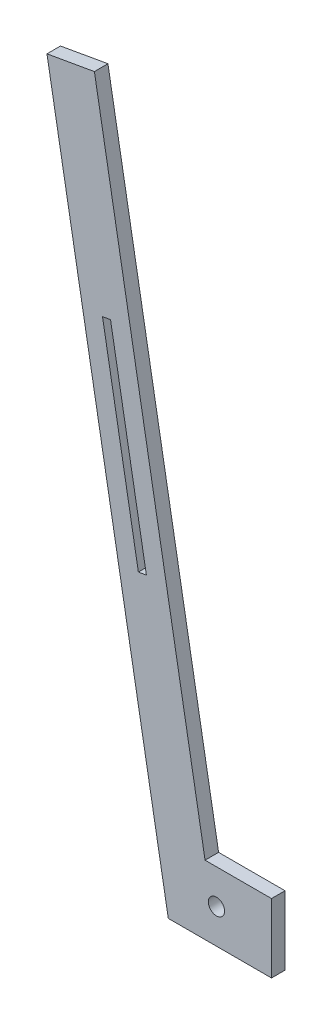
from build123d import *

# Parameters (mm, degrees)
SKETCH1_R           = 3
BOSS_EXTRUDE1_DEPTH = 2.5
CUT_EXTRUDE1_DEPTH  = 6
CUT_EXTRUDE2_DEPTH  = 25.4


with BuildPart() as part:
    # Sketch1 → Boss-Extrude1 (new body, symmetric)
    with BuildSketch(Plane.XY):
        Polygon((20.32, 12.7), (20.32, -12.7), (-17.78, -12.7), (-62.5670531, 241.3), (-37.552936173, 245.710663713), (3.533130632, 12.7), align=None)
        Circle(SKETCH1_R, mode=Mode.SUBTRACT)
    extrude(amount=BOSS_EXTRUDE1_DEPTH, both=True)

    # Sketch2 → Cut-Extrude1 (cut, through all)
    with BuildSketch(Plane.XY.offset(2.5)):
        Polygon((-37.552936173, 245.710663713), (3.533130632, 12.7), (-4.204420151, 12.7), (-45.057171251, 244.387464599), align=None)
    extrude(amount=-CUT_EXTRUDE1_DEPTH, mode=Mode.SUBTRACT)

    # Sketch3 → Cut-Extrude2 (cut, symmetric)
    with BuildSketch(Plane.XY):
        Polygon((-42.057332667, 167.540909253), (-39.102909408, 168.061853786), (-25.87091827, 93.019503007), (-28.825341529, 92.498558474), align=None)
    extrude(amount=CUT_EXTRUDE2_DEPTH, both=True, mode=Mode.SUBTRACT)


solid = part.part
